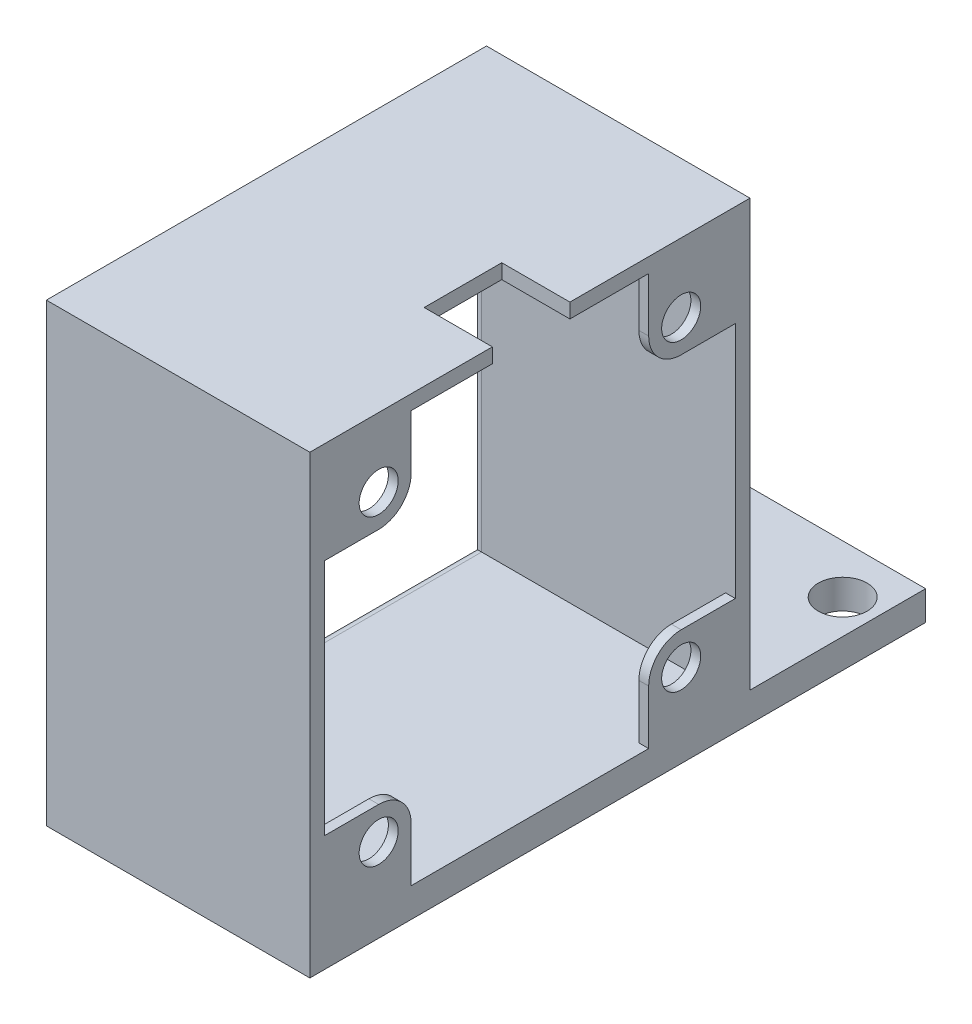
from build123d import *

# Parameters (mm, degrees)
SKETCH1_W           = 27
SKETCH1_H           = 63.1
SKETCH1_R           = 2.5
BOSS_EXTRUDE1_DEPTH = 3
SKETCH2_W           = 27
SKETCH2_H           = 45.1
BOSS_EXTRUDE2_DEPTH = 43.66
CUT_EXTRUDE1_DEPTH  = 28
SKETCH3_8_W         = 42.1
SKETCH3_8_H         = 42.16
SKETCH3_8_R         = 2
CUT_EXTRUDE2_DEPTH  = 26
FILLET4_R           = 1
SKETCH6_W           = 6.985
SKETCH6_H           = 7.95
CUT_EXTRUDE3_DEPTH  = 1.5
SKETCH3_9_R         = 2
CUT_EXTRUDE4_DEPTH  = 28


with BuildPart() as part:
    # Sketch1 → Boss-Extrude1 (new body)
    with BuildSketch(Plane(origin=(0, 0, 0), x_dir=(1, 0, 0), z_dir=(0, 1, 0))):
        with Locations((13.5, 31.55)):
            Rectangle(SKETCH1_W, SKETCH1_H)
        with Locations((3.5, 58.1)):
            Circle(SKETCH1_R, mode=Mode.SUBTRACT)
        with Locations((23.5, 58.1)):
            Circle(SKETCH1_R, mode=Mode.SUBTRACT)
    extrude(amount=BOSS_EXTRUDE1_DEPTH)

    # Sketch2 → Boss-Extrude2 (add)
    with BuildSketch(Plane(origin=(0, 3, 0), x_dir=(1, 0, 0), z_dir=(0, 1, 0))):
        with Locations((13.5, 22.55)):
            Rectangle(SKETCH2_W, SKETCH2_H)
    extrude(amount=BOSS_EXTRUDE2_DEPTH)

    # Sketch3 → Cut-Extrude1 (cut, through all)
    with BuildSketch(Plane.ZY):
        with BuildLine():
            Line((-10.38, 45.16), (-34.72, 45.16))
            Line((-34.72, 45.16), (-34.72, 39.61))
            ThreePointArc((-34.72, 39.61), (-35.695334419, 37.255334419), (-38.05, 36.28))
            Line((-38.05, 36.28), (-43.6, 36.28))
            Line((-43.6, 36.28), (-43.6, 11.88))
            Line((-43.6, 11.88), (-38.05, 11.88))
            ThreePointArc((-38.05, 11.88), (-35.695334419, 10.904665581), (-34.72, 8.55))
            Line((-34.72, 8.55), (-34.72, 3))
            Line((-34.72, 3), (-10.38, 3))
            Line((-10.38, 3), (-10.38, 8.55))
            ThreePointArc((-10.38, 8.55), (-9.404665581, 10.904665581), (-7.05, 11.88))
            Line((-7.05, 11.88), (-1.5, 11.88))
            Line((-1.5, 11.88), (-1.5, 36.28))
            Line((-1.5, 36.28), (-7.05, 36.28))
            ThreePointArc((-7.05, 36.28), (-9.404665581, 37.255334419), (-10.38, 39.61))
            Line((-10.38, 39.61), (-10.38, 45.16))
        make_face()
    extrude(amount=-CUT_EXTRUDE1_DEPTH, mode=Mode.SUBTRACT)

    # Sketch3_8 → Cut-Extrude2 (cut)
    with BuildSketch(Plane.ZY):
        with Locations((-22.55, 24.08)):
            Rectangle(SKETCH3_8_W, SKETCH3_8_H)
        with Locations((-38.05, 8.55)):
            Circle(SKETCH3_8_R, mode=Mode.SUBTRACT)
        with Locations((-7.05, 39.61)):
            Circle(SKETCH3_8_R, mode=Mode.SUBTRACT)
        with Locations((-7.05, 8.55)):
            Circle(SKETCH3_8_R, mode=Mode.SUBTRACT)
        with Locations((-38.05, 39.61)):
            Circle(SKETCH3_8_R, mode=Mode.SUBTRACT)
    extrude(amount=-CUT_EXTRUDE2_DEPTH, mode=Mode.SUBTRACT)

    # Fillet4
    fillet4_edges = [part.edges().sort_by_distance(p)[0] for p in [
        (0, 45.16, -22.55),
        (0, 24.08, -1.5),
        (0, 3, -22.55),
        (0, 24.08, -43.6),
    ]]
    fillet(fillet4_edges, radius=FILLET4_R)

    # Sketch6 → Cut-Extrude3 (cut)
    with BuildSketch(Plane(origin=(0, 46.66, 0), x_dir=(1, 0, 0), z_dir=(0, 1, 0))):
        with Locations((23.5075, 22.675)):
            Rectangle(SKETCH6_W, SKETCH6_H)
    extrude(amount=-CUT_EXTRUDE3_DEPTH, mode=Mode.SUBTRACT)

    # Sketch3_9 → Cut-Extrude4 (cut, through all)
    with BuildSketch(Plane.ZY):
        with Locations((-38.05, 39.61)):
            Circle(SKETCH3_9_R)
        with Locations((-7.05, 39.61)):
            Circle(SKETCH3_9_R)
        with Locations((-7.05, 8.55)):
            Circle(SKETCH3_9_R)
        with Locations((-38.05, 8.55)):
            Circle(SKETCH3_9_R)
    extrude(amount=-CUT_EXTRUDE4_DEPTH, mode=Mode.SUBTRACT)


solid = part.part
